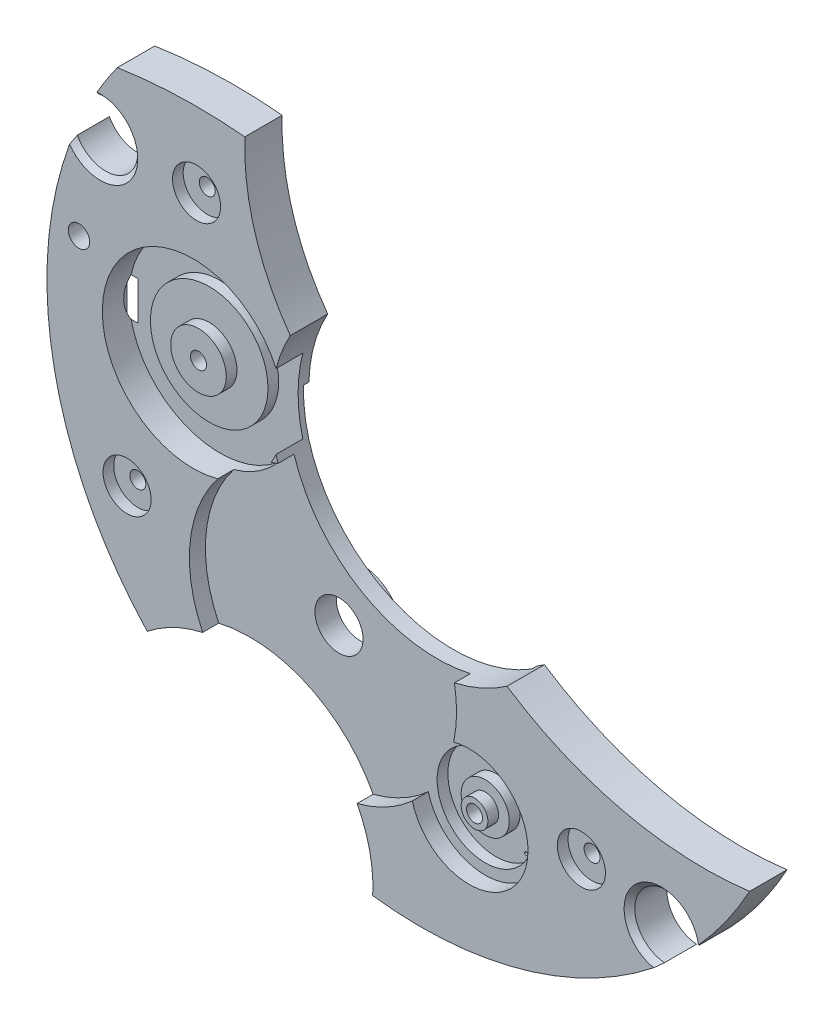
from build123d import *

# Parameters (mm, degrees)
CROQUIS2_R                 = 1.125
CROQUIS2_R_2               = 0.5
SALIENTE_EXTRUIR1_DEPTH    = 1.75
CORTAR_EXTRUIR1_DEPTH      = 0.75
CROQUIS4_R                 = 8.5
CORTAR_EXTRUIR2_DEPTH      = 0.25
CROQUIS5_R                 = 2.25
CROQUIS5_R_2               = 1.125
CORTAR_EXTRUIR3_DEPTH      = 0.5
CROQUIS6_R                 = 0.625
SALIENTE_EXTRUIR2_DEPTH    = 0.5
CROQUIS7_R                 = 4.25
CORTAR_EXTRUIR4_DEPTH      = 1.25
CROQUIS8_R                 = 2.75
SALIENTE_EXTRUIR3_DEPTH    = 0.5
CROQUIS9_R                 = 1.3
SALIENTE_EXTRUIR4_DEPTH    = 0.5
CROQUIS10_R                = 0.075
CORTAR_EXTRUIR5_DEPTH      = 1.5
CROQUIS11_R                = 1.125
CORTAR_EXTRUIR6_DEPTH      = 0.5
TALADRO_ROSCADO_M1X0_251_D = 0.75
TALADRO_ROSCADO_M1X0_253_D = 0.75
CHAFL_N1_SIZE              = 0.25
CROQUIS16_R                = 2
CROQUIS16_R_2              = 1.125
SALIENTE_EXTRUIR5_DEPTH    = 0.25
CROQUIS19_R                = 1.75
CORTAR_EXTRUIR7_DEPTH      = 1
CROQUIS20_R                = 1.25
CORTAR_EXTRUIR8_DEPTH      = 3
TALADRO_ROSCADO_M1X0_252_D = 0.75


with BuildPart() as part:
    # Croquis2 → Saliente-Extruir1 (new body)
    with BuildSketch(Plane.XY):
        with BuildLine():
            ThreePointArc((-16.326658805, 6.300016846), (-17.182882286, -3.316407146), (-12.80940905, -11.92346593))
            ThreePointArc((-12.80940905, -11.92346593), (-5.775317693, -11.220617232), (-2.259619844, -17.353504492))
            ThreePointArc((-2.259619844, -17.353504492), (4.841189817, -16.817041391), (11.1403887, -13.49598976))
            ThreePointArc((11.1403887, -13.49598976), (10.224088307, -10.905694194), (12.74994394, -11.987031723))
            ThreePointArc((12.74994394, -11.987031723), (14.176723516, -10.260141829), (15.371220143, -8.365141441))
            ThreePointArc((15.371220143, -8.365141441), (9.460159173, -8.065624613), (4.022288522, -5.728978535))
            ThreePointArc((4.022288522, -5.728978535), (-4.686054245, -5.200086116), (-6.115237098, 3.406446129))
            ThreePointArc((-6.115237098, 3.406446129), (-7.762325395, 6.723591586), (-8.243034525, 10.395821504))
            ThreePointArc((-8.243034525, 10.395821504), (-11.230553814, 10.48910556), (-14.20719972, 10.21789979))
            ThreePointArc((-14.20719972, 10.21789979), (-14.787393079, 9.358579269), (-15.315676961, 8.466406511))
            ThreePointArc((-15.315676961, 8.466406511), (-13.64072529, 6.365671802), (-16.326658805, 6.300016846))
        make_face()
        with Locations((-4.5875, -7.94578308)):
            Circle(CROQUIS2_R, mode=Mode.SUBTRACT)
        with Locations((-16, 2.5)):
            Circle(CROQUIS2_R_2, mode=Mode.SUBTRACT)
    extrude(amount=SALIENTE_EXTRUIR1_DEPTH)

    # Croquis3 → Cortar-Extruir1 (cut)
    with BuildSketch(Plane.XY.offset(1.75)):
        with BuildLine():
            ThreePointArc((1.526213137, -9.243863075), (-10.000158774, -4.82078308), (-0.406473179, -12.59137397))
            ThreePointArc((-0.406473179, -12.59137397), (4.63567055, -13.27078308), (1.526213137, -9.243863075))
        make_face()
    extrude(amount=-CORTAR_EXTRUIR1_DEPTH, mode=Mode.SUBTRACT)

    # Croquis4 → Cortar-Extruir2 (cut)
    with BuildSketch(Plane(origin=(0, 0, 0), x_dir=(-1, 0, 0), z_dir=(0, 0, -1))):
        with Locations((4.5875, -7.94578308)):
            Circle(CROQUIS4_R)
    extrude(amount=-CORTAR_EXTRUIR2_DEPTH, mode=Mode.SUBTRACT)

    # Croquis5 → Cortar-Extruir3 (cut)
    with BuildSketch(Plane.XY.offset(1)):
        with Locations((2.25410069, -11.89578308)):
            Circle(CROQUIS5_R)
        with Locations((2.25410069, -11.89578308)):
            Circle(CROQUIS5_R_2, mode=Mode.SUBTRACT)
    extrude(amount=-CORTAR_EXTRUIR3_DEPTH, mode=Mode.SUBTRACT)

    # Croquis6 → Saliente-Extruir2 (add)
    with BuildSketch(Plane.XY.offset(1)):
        with Locations((2.25410069, -11.89578308)):
            Circle(CROQUIS6_R)
    extrude(amount=SALIENTE_EXTRUIR2_DEPTH)

    # Croquis7 → Cortar-Extruir4 (cut)
    with BuildSketch(Plane.XY.offset(1.75)):
        with Locations((-10.659116856, 0)):
            Circle(CROQUIS7_R)
    extrude(amount=-CORTAR_EXTRUIR4_DEPTH, mode=Mode.SUBTRACT)

    # Croquis8 → Saliente-Extruir3 (add)
    with BuildSketch(Plane.XY.offset(0.5)):
        with Locations((-10.659116856, 0)):
            Circle(CROQUIS8_R)
    extrude(amount=SALIENTE_EXTRUIR3_DEPTH)

    # Croquis9 → Saliente-Extruir4 (add)
    with BuildSketch(Plane.XY.offset(1)):
        with Locations((-10.659116856, 0)):
            Circle(CROQUIS9_R)
    extrude(amount=SALIENTE_EXTRUIR4_DEPTH)

    # Croquis10 → Cortar-Extruir5 (cut, through all)
    with BuildSketch(Plane.XY.offset(0.5)):
        with Locations((3.668314252, -13.309996642)):
            Circle(CROQUIS10_R)
    extrude(amount=-CORTAR_EXTRUIR5_DEPTH, mode=Mode.SUBTRACT)

    # Croquis11 → Cortar-Extruir6 (cut)
    with BuildSketch(Plane.XY.offset(1.75)):
        with Locations((-13.75, -6.5)):
            Circle(CROQUIS11_R)
        with Locations((-10.5, 7)):
            Circle(CROQUIS11_R)
        with Locations((7.5, -11)):
            Circle(CROQUIS11_R)
    extrude(amount=-CORTAR_EXTRUIR6_DEPTH, mode=Mode.SUBTRACT)

    # Taladro roscado M1x0.251 (through all)
    with Locations(Plane.XY.offset(1.5)):
        with Locations((2.25410069, -11.89578308)):
            Hole(TALADRO_ROSCADO_M1X0_251_D / 2)

    # Taladro roscado M1x0.253 (through all)
    with Locations(Plane.XY.offset(1.5)):
        with Locations((-10.659116856, 0)):
            Hole(TALADRO_ROSCADO_M1X0_253_D / 2)

    # Chaflán1
    chafl_n1_edges = [part.edges().sort_by_distance(p)[0] for p in [
        (10.224088307, -10.905694194, 1.75),
        (-13.64072529, 6.365671802, 1.75),
    ]]
    chamfer(chafl_n1_edges, length=CHAFL_N1_SIZE)

    # Croquis16 → Saliente-Extruir5 (add)
    with BuildSketch(Plane(origin=(0, 0, 0.25), x_dir=(-1, 0, 0), z_dir=(0, 0, -1))):
        with Locations((4.5875, -7.94578308)):
            Circle(CROQUIS16_R)
        with Locations((4.5875, -7.94578308)):
            Circle(CROQUIS16_R_2, mode=Mode.SUBTRACT)
    extrude(amount=SALIENTE_EXTRUIR5_DEPTH)

    # Croquis19 → Cortar-Extruir7 (cut)
    with BuildSketch(Plane(origin=(-14.5, 0, 0), x_dir=(0, 0, -1), z_dir=(1, 0, 0))):
        with Locations((1, 0)):
            Circle(CROQUIS19_R)
    extrude(amount=-CORTAR_EXTRUIR7_DEPTH, mode=Mode.SUBTRACT)

    # Croquis20 → Cortar-Extruir8 (cut)
    with BuildSketch(Plane.ZY.offset(14.5)):
        with Locations((-1, 0)):
            Circle(CROQUIS20_R)
    extrude(amount=-CORTAR_EXTRUIR8_DEPTH, mode=Mode.SUBTRACT)

    # Taladro roscado M1x0.252 (through all)
    with Locations(Plane.XY.offset(1.25)):
        with Locations((-13.75, -6.5), (-10.5, 7), (7.5, -11)):
            Hole(TALADRO_ROSCADO_M1X0_252_D / 2)


solid = part.part
